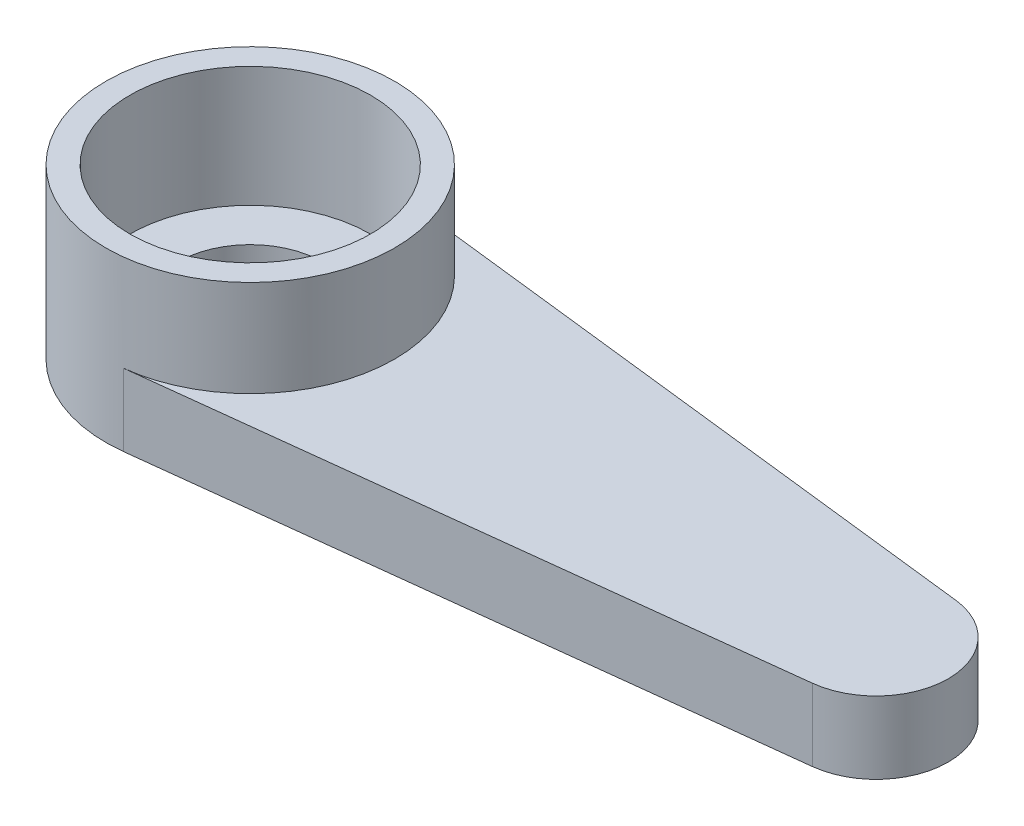
from build123d import *

# Parameters (mm, degrees)
SKETCH1_R           = 1.5
BOSS_EXTRUDE1_DEPTH = 1.5
SKETCH2_R           = 3
SKETCH2_R_2         = 2.5
BOSS_EXTRUDE2_DEPTH = 2
SKETCH3_R           = 2.5
CUT_EXTRUDE1_DEPTH  = 0.5


with BuildPart() as part:
    # Sketch1 → Boss-Extrude1 (new body)
    with BuildSketch(Plane(origin=(0, 0, 0), x_dir=(1, 0, 0), z_dir=(0, 1, 0))):
        with BuildLine():
            Line((0.346153846, 2.97996267), (13.173076923, 1.489981335))
            ThreePointArc((13.173076923, 1.489981335), (14.5, 0), (13.173076923, -1.489981335))
            Line((13.173076923, -1.489981335), (0.346153846, -2.97996267))
            ThreePointArc((0.346153846, -2.97996267), (-3, 0), (0.346153846, 2.97996267))
        make_face()
        Circle(SKETCH1_R, mode=Mode.SUBTRACT)
    extrude(amount=BOSS_EXTRUDE1_DEPTH)

    # Sketch2 → Boss-Extrude2 (add)
    with BuildSketch(Plane(origin=(0, 1.5, 0), x_dir=(1, 0, 0), z_dir=(0, 1, 0))):
        Circle(SKETCH2_R)
        Circle(SKETCH2_R_2, mode=Mode.SUBTRACT)
    extrude(amount=BOSS_EXTRUDE2_DEPTH)

    # Sketch3 → Cut-Extrude1 (cut)
    with BuildSketch(Plane(origin=(0, 1.5, 0), x_dir=(1, 0, 0), z_dir=(0, 1, 0))):
        Circle(SKETCH3_R)
    extrude(amount=-CUT_EXTRUDE1_DEPTH, mode=Mode.SUBTRACT)


solid = part.part
